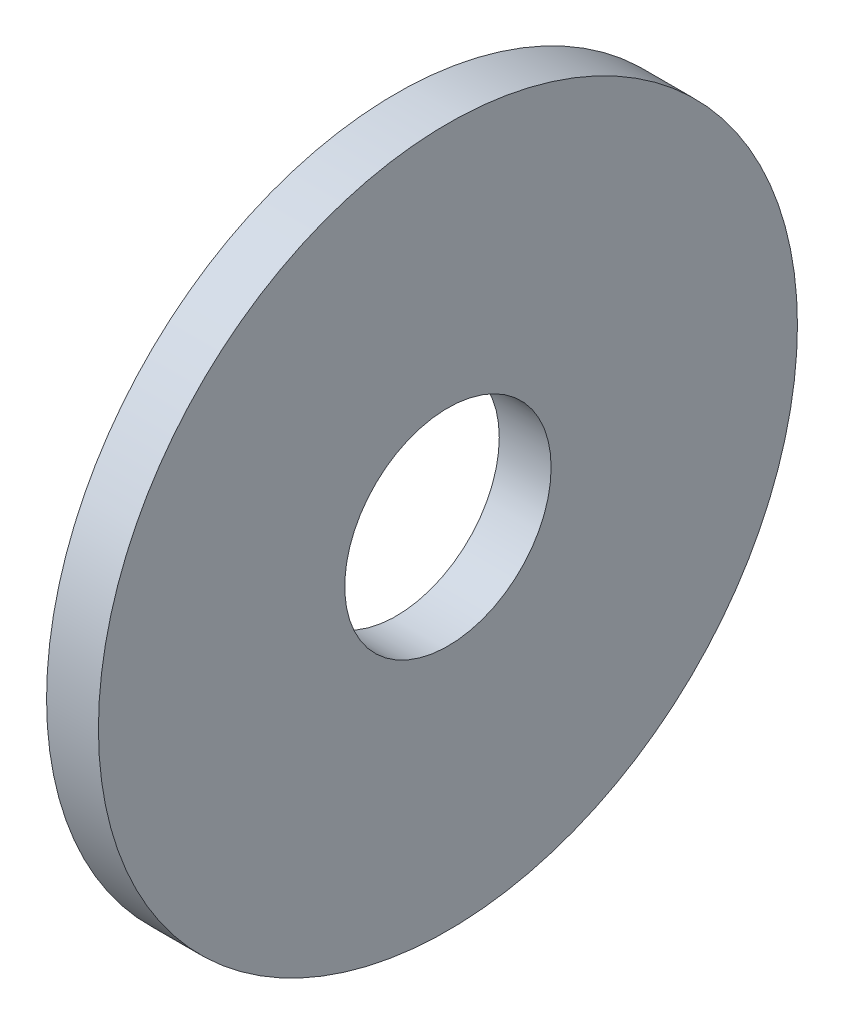
from build123d import *

# Parameters (mm, degrees)
SKETCH1_R           = 8.73125
SKETCH1_R_2         = 2.5781
BOSS_EXTRUDE1_DEPTH = 1.2954


with BuildPart() as part:
    # Sketch1 → Boss-Extrude1 (new body)
    with BuildSketch(Plane(origin=(0, 0, 0), x_dir=(0, 0, -1), z_dir=(1, 0, 0))):
        Circle(SKETCH1_R)
        Circle(SKETCH1_R_2, mode=Mode.SUBTRACT)
    extrude(amount=BOSS_EXTRUDE1_DEPTH)


solid = part.part
